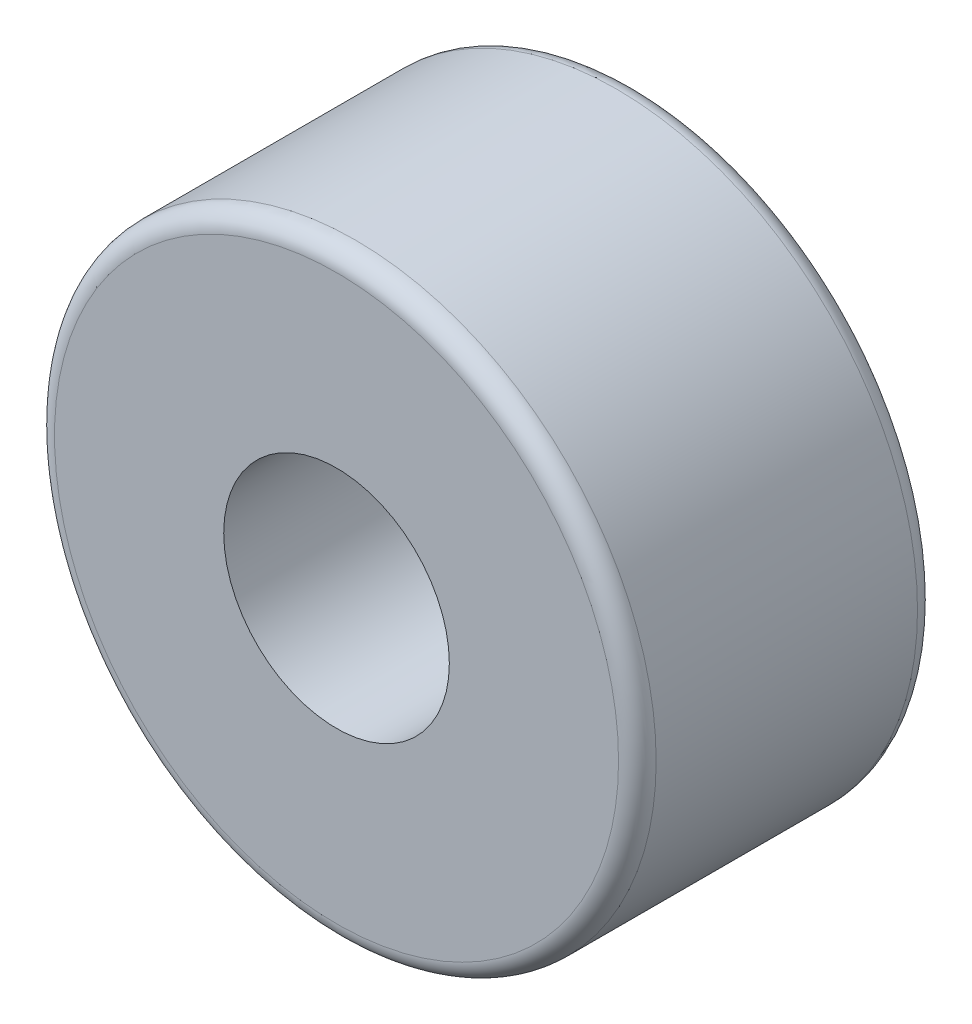
from build123d import *

# Parameters (mm, degrees)
SKETCH1_R           = 16
SKETCH1_R_2         = 6
BOSS_EXTRUDE1_DEPTH = 15.9
FILLET1_R           = 1


with BuildPart() as part:
    # Sketch1 → Boss-Extrude1 (new body)
    with BuildSketch(Plane.XY):
        Circle(SKETCH1_R)
        Circle(SKETCH1_R_2, mode=Mode.SUBTRACT)
    extrude(amount=BOSS_EXTRUDE1_DEPTH)

    # Fillet1
    fillet1_edges = [part.edges().sort_by_distance(p)[0] for p in [
        (-16, 0, 0),
        (-16, 0, 15.9),
    ]]
    fillet(fillet1_edges, radius=FILLET1_R)


solid = part.part
